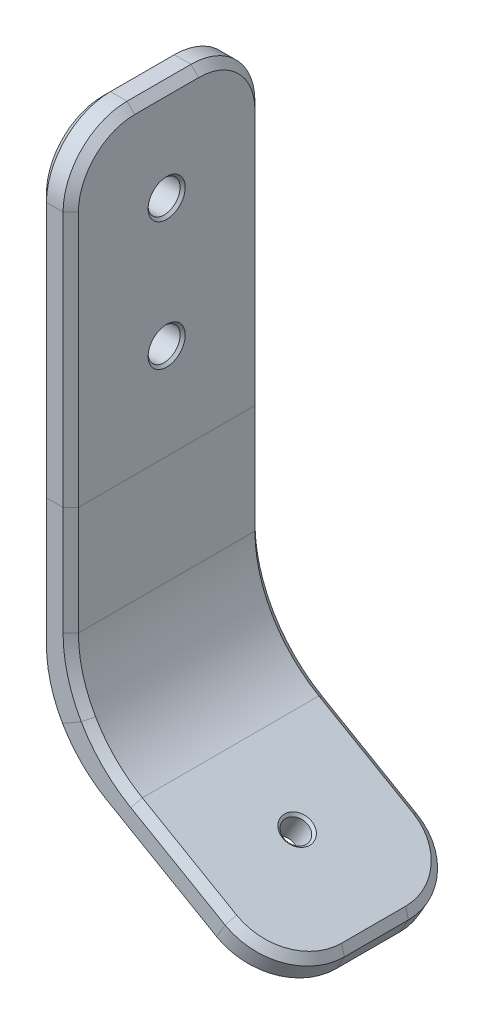
from build123d import *

# Parameters (mm, degrees)
SKETCH2_W                       = 3.175
SKETCH2_H                       = 19.05
F_1_8_0_125_DIAMETER_HOLE1_D    = 3.175
F_3_32_0_09375_DIAMETER_HOLE2_D = 2.38125
FILLET1_R                       = 12.7
FILLET2_R                       = 6.35
CHAMFER3_SIZE                   = 0.762
CHAMFER2_SIZE                   = 0.254


with BuildPart() as part:
    # Sweep1: sweep along a path in Sketch1
    with BuildLine(Plane.XY) as sweep1_path:
        Line((0, 0), (0, -31.75))
        Line((0, -31.75), (0, -50.8))
        Line((0, -50.8), (21.997045256, -63.5))
    # Sketch2 → Sweep1 (sweep)
    with BuildSketch(Plane(origin=(0, 0, 0), x_dir=(1, 0, 0), z_dir=(0, 1, 0))):
        Rectangle(SKETCH2_W, SKETCH2_H)
    sweep(path=sweep1_path.line, transition=Transition.RIGHT)

    # 1/8 (0.125) Diameter Hole1 (through all)
    with Locations(Plane(origin=(1.5875, 0, 0), x_dir=(0, 0, -1), z_dir=(1, 0, 0))):
        with Locations((0, -9.525), (0, -22.225)):
            Hole(F_1_8_0_125_DIAMETER_HOLE1_D / 2)

    # 3/32 (0.09375) Diameter Hole2 (through all)
    with Locations(Plane(origin=(-21.203295256, -36.725184671, 0), x_dir=(0.866025404, -0.5, 0), z_dir=(0.5, 0.866025404, 0))):
        with Locations((41.275, 0)):
            Hole(F_3_32_0_09375_DIAMETER_HOLE2_D / 2)

    # Fillet1
    fillet1_edges = [part.edges().sort_by_distance(p)[0] for p in [
        (1.5875, -49.883456448, 0),
        (-1.5875, -51.716543552, 0),
    ]]
    fillet(fillet1_edges, radius=FILLET1_R)

    # Fillet2
    fillet2_edges = [part.edges().sort_by_distance(p)[0] for p in [
        (21.997045256, -63.5, -9.525),
        (21.997045256, -63.5, 9.525),
        (0, 0, -9.525),
        (0, 0, 9.525),
    ]]
    fillet(fillet2_edges, radius=FILLET2_R)

    # Chamfer3
    chamfer3_edges = [part.edges().sort_by_distance(p)[0] for p in [
        (10.233266971, -58.541266545, -9.525),
        (10.233266971, -58.541266545, 9.525),
        (12.614516971, -56.249907664, -9.525),
        (0.113977372, -50.734195134, -9.525),
        (0.113977372, -50.734195134, -9.525),
        (0.113977372, -50.734195134, 9.525),
        (12.614516971, -56.249907664, 9.525),
        (0.113977372, -50.734195134, 9.525),
        (3.288977372, -48.901108029, 9.525),
        (3.288977372, -48.901108029, 9.525),
        (3.288977372, -48.901108029, -9.525),
        (3.288977372, -48.901108029, -9.525),
        (1.5875, -24.450554014, 9.525),
        (1.5875, -24.450554014, -9.525),
        (-1.5875, -25.367097567, -9.525),
        (-1.5875, -25.367097567, 9.525),
        (21.203295256, -64.874815329, 0),
        (19.592598909, -63.944879359, 7.665128061),
        (19.592598909, -63.944879359, -7.665128061),
        (22.790795256, -62.125184671, 0),
        (21.180098909, -61.195248702, 7.665128061),
        (21.180098909, -61.195248702, -7.665128061),
        (1.5875, 0, 0),
        (-1.5875, 0, 0),
        (-1.5875, -25.367097567, 9.525),
        (-1.5875, -25.367097567, -9.525),
        (-1.5875, -1.859871939, 7.665128061),
        (-1.5875, -1.859871939, -7.665128061),
        (1.5875, -24.450554014, -9.525),
        (1.5875, -24.450554014, 9.525),
        (1.5875, -1.859871939, 7.665128061),
        (1.5875, -1.859871939, -7.665128061),
    ]]
    chamfer(chamfer3_edges, length=CHAMFER3_SIZE)

    # Chamfer2
    chamfer2_edges = [part.edges().sort_by_distance(p)[0] for p in [
        (1.5875, -22.225, -1.5875),
        (-1.5875, -22.225, -1.5875),
        (1.5875, -9.525, -1.5875),
        (-1.5875, -9.525, -1.5875),
        (13.985514781, -60.707627829, 0),
        (15.573014781, -57.957997171, 0),
    ]]
    chamfer(chamfer2_edges, length=CHAMFER2_SIZE)


solid = part.part
